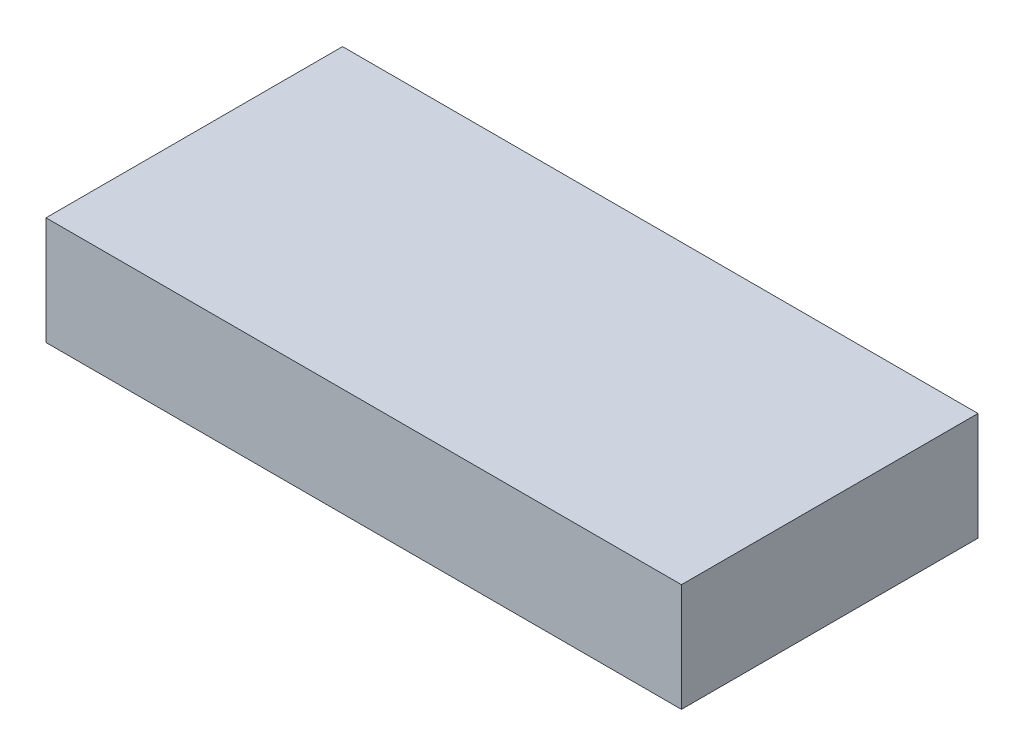
from build123d import *

# Parameters (mm, degrees)
SKETCH_2_W      = 60
SKETCH_2_H      = 28
EXTRUDE_1_DEPTH = 10.2
SKETCH_3_R      = 7
EXTRUDE_2_DEPTH = 2.4


with BuildPart() as part:
    # 草图2 → 凸台-拉伸1 (new body)
    with BuildSketch(Plane(origin=(0, 0, 0), x_dir=(1, 0, 0), z_dir=(0, 1, 0))):
        with Locations((10.280701754, -4.807017544)):
            Rectangle(SKETCH_2_W, SKETCH_2_H)
    extrude(amount=EXTRUDE_1_DEPTH)

    # 草图3 → 凸台-拉伸2 (add)
    with BuildSketch(Plane.XZ):
        with Locations((21.280701754, 4.807017544)):
            Circle(SKETCH_3_R)
    extrude(amount=EXTRUDE_2_DEPTH)


solid = part.part
